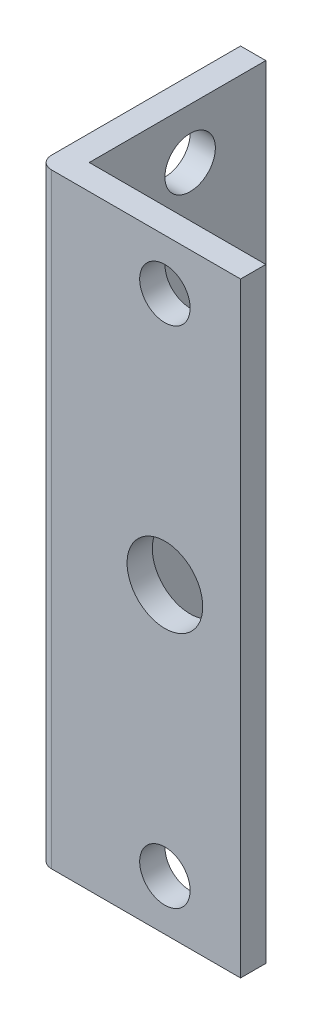
from build123d import *

# Parameters (mm, degrees)
SKETCH1_W                                 = 76.2
SKETCH1_H                                 = 25.4
BOSS_EXTRUDE1_DEPTH                       = 25.4
SKETCH2_W                                 = 22.225
SKETCH2_H                                 = 22.225
CUT_EXTRUDE1_DEPTH                        = 77.2
FILLET1_R                                 = 1.5875
F_1_4_0_25_DIAMETER_HOLE4_D               = 6.35
F_1_4_0_25_DIAMETER_HOLE4_DEPTH           = 3.175
F_1_4_0_25_DIAMETER_HOLE4_ON_FACE_2_D     = 6.35
F_1_4_0_25_DIAMETER_HOLE4_ON_FACE_2_DEPTH = 3.175
F_3_8_0_375_DIAMETER_HOLE1_D              = 9.525
F_3_8_0_375_DIAMETER_HOLE1_ON_FACE_2_D    = 9.525


with BuildPart() as part:
    # Sketch1 → Boss-Extrude1 (new body)
    with BuildSketch(Plane(origin=(-13.984269616, 0, 0), x_dir=(0, -1, 0), z_dir=(-1, 0, 0))):
        with Locations((0, -0.588041782)):
            Rectangle(SKETCH1_W, SKETCH1_H)
    extrude(amount=-BOSS_EXTRUDE1_DEPTH)

    # Sketch2 → Cut-Extrude1 (cut, through all)
    with BuildSketch(Plane.XZ.offset(38.1)):
        with Locations((0.303230384, -2.175541782)):
            Rectangle(SKETCH2_W, SKETCH2_H)
    extrude(amount=-CUT_EXTRUDE1_DEPTH, mode=Mode.SUBTRACT)

    # Fillet1
    fillet1_edges = [part.edges().sort_by_distance(p)[0] for p in [
        (-13.984269616, 0, 12.111958218),
    ]]
    fillet(fillet1_edges, radius=FILLET1_R)

    # 1/4 (0.25) Diameter Hole4
    with Locations(Plane(origin=(1.890730384, 31.75, 12.111958218), x_dir=(1, 0, 0), z_dir=(0, 0, 1))):
        with Locations((0, 0), (0, -63.5)):
            Hole(F_1_4_0_25_DIAMETER_HOLE4_D / 2, depth=F_1_4_0_25_DIAMETER_HOLE4_DEPTH)

    # 1/4 (0.25) Diameter Hole4 on face 2
    with Locations(Plane(origin=(-13.984269616, 31.75, -3.763041782), x_dir=(0, 0, -1), z_dir=(-1, 0, 0))):
        with Locations((0, 0), (0, 63.5)):
            Hole(F_1_4_0_25_DIAMETER_HOLE4_ON_FACE_2_D / 2, depth=F_1_4_0_25_DIAMETER_HOLE4_ON_FACE_2_DEPTH)

    # 3/8 (0.375) Diameter Hole1 (through all)
    with Locations(Plane(origin=(-13.984269616, 0, -3.763041782), x_dir=(0, 0, -1), z_dir=(-1, 0, 0))):
        with Locations((0, 0)):
            Hole(F_3_8_0_375_DIAMETER_HOLE1_D / 2)

    # 3/8 (0.375) Diameter Hole1 on face 2 (through all)
    with Locations(Plane(origin=(1.890730384, 0, 12.111958218), x_dir=(1, 0, 0), z_dir=(0, 0, 1))):
        with Locations((0, 0)):
            Hole(F_3_8_0_375_DIAMETER_HOLE1_ON_FACE_2_D / 2)


solid = part.part
